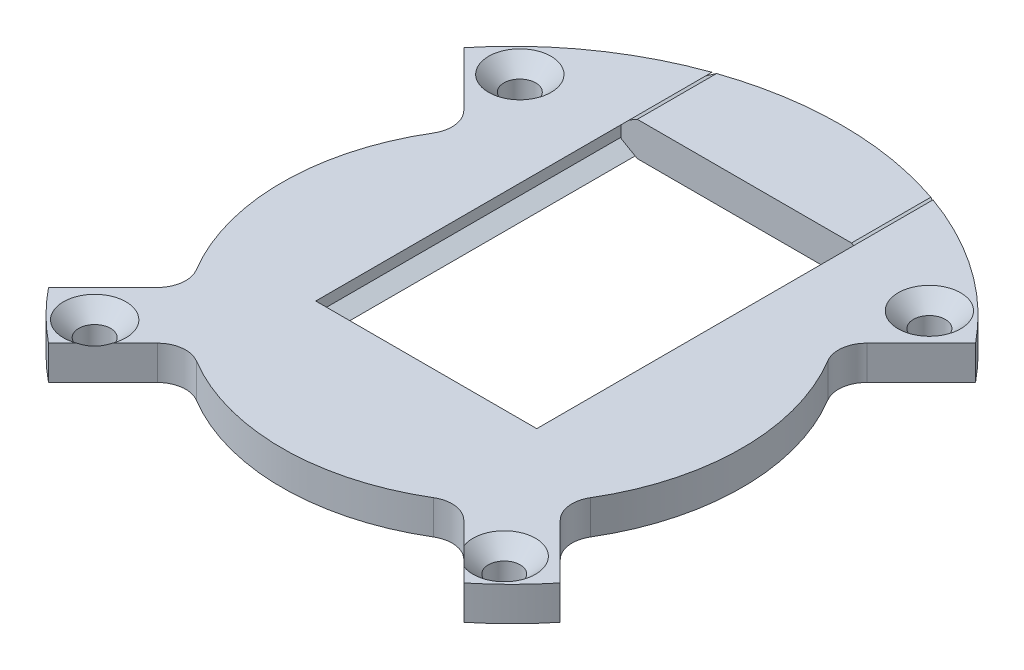
from build123d import *

# Parameters (mm, degrees)
SKETCH1_R                                      = 29
BOSS_EXTRUDE1_DEPTH                            = 1.5
CUT_EXTRUDE1_DEPTH                             = 42.12177039
BOSS_EXTRUDE2_REACH                            = 46.997
BOSS_EXTRUDE2_END_RADIUS                       = 29
BOSS_EXTRUDE3_REACH                            = 59.346
BOSS_EXTRUDE3_END_RADIUS                       = 29
CUT_EXTRUDE8_DEPTH                             = 42.12177039
CSK_FOR_M2_5_FLAT_HEAD_MACHINE_SCREW2_AT_COUNT = 2
CSK_FOR_M2_5_FLAT_HEAD_MACHINE_SCREW2_AT_PITCH = 36.043
CSK_FOR_M2_5_FLAT_HEAD_MACHINE_SCREW_2_COUNT   = 2
CSK_FOR_M2_5_FLAT_HEAD_MACHINE_SCREW_2_PITCH   = 51.950988874
CSK_FOR_M2_5_FLAT_HEAD_MACHINE_SCREW_3_COUNT   = 2
CSK_FOR_M2_5_FLAT_HEAD_MACHINE_SCREW_3_PITCH   = 37.414


with BuildPart() as part:
    # Sketch1 → Boss-Extrude1 (new, symmetric)
    with BuildSketch(Plane(origin=(0, 0, 0), x_dir=(1, 0, 0), z_dir=(0, 1, 0))):
        with Locations(Location((0, 0, 0), (0, 0, 270))):
            Circle(SKETCH1_R)
    extrude(amount=BOSS_EXTRUDE1_DEPTH, both=True)

    # Sketch2 → Cut-Extrude1 (cut, through all)
    with BuildSketch(Plane(origin=(0, 1.5, 0), x_dir=(1, 0, 0), z_dir=(0, 1, 0))):
        Polygon((-11.025, 7.55), (-11.025, 29), (11.025, 29), (11.025, 7.55), (11.025, -7.55), (-11.025, -7.55), align=None)
    extrude(amount=-CUT_EXTRUDE1_DEPTH, mode=Mode.SUBTRACT)

    # Boss-Extrude2: up to this cylinder (the profile starts inside it)
    boss_extrude2_end = Plane(origin=(0, -0.7325095, 0), z_dir=(0, -1, 0)) * Cylinder(BOSS_EXTRUDE2_END_RADIUS, 154.459019, mode=Mode.PRIVATE)
    # Sketch3 → Boss-Extrude2 (add, up to the surface)
    with BuildSketch(Plane(origin=(0, 0, 7.55), x_dir=(-1, 0, 0), z_dir=(0, 0, -1)), mode=Mode.PRIVATE) as boss_extrude2_sk1:
        Polygon((-11.525, -1.5), (-9.725961894, -1.5), (-11.025, -0.75), (-11.025, 0.75), (-9.725961894, 1.5), (-11.525, 1.5), align=None)
    boss_extrude2_tool1 = extrude(boss_extrude2_sk1.sketch, amount=BOSS_EXTRUDE2_REACH, mode=Mode.PRIVATE) & boss_extrude2_end
    add(boss_extrude2_tool1.solids().sort_by_distance((10.625481, -1.465019, 7.55))[0])
    # Sketch3 → Boss-Extrude2 (add, up to the surface)
    with BuildSketch(Plane(origin=(0, 0, 7.55), x_dir=(-1, 0, 0), z_dir=(0, 0, -1)), mode=Mode.PRIVATE) as boss_extrude2_sk2:
        Polygon((11.525, 1.5), (11.525, -1.5), (9.725961894, -1.5), (11.025, -0.75), (11.025, 0.75), (9.725961894, 1.5), align=None)
    boss_extrude2_tool2 = extrude(boss_extrude2_sk2.sketch, amount=BOSS_EXTRUDE2_REACH, mode=Mode.PRIVATE) & boss_extrude2_end
    add(boss_extrude2_tool2.solids().sort_by_distance((-11.490019, 0, 7.55))[0])

    # Sketch17 → Cut-Extrude8 (cut, through all)
    with BuildSketch(Plane(origin=(0, 1.5, 0), x_dir=(1, 0, 0), z_dir=(0, 1, 0))):
        with BuildLine():
            ThreePointArc((-22.517398398, 18.274757711), (-29, 0), (-22.517398398, -18.274757711))
            Line((-22.517398398, -18.274757711), (-17.730812648, -13.488171961))
            ThreePointArc((-17.730812648, -13.488171961), (-17.017188537, -12.024869111), (-17.355878546, -10.432448414))
            ThreePointArc((-17.355878546, -10.432448414), (-20.25, 0), (-17.355878546, 10.432448414))
            ThreePointArc((-17.355878546, 10.432448414), (-17.017188537, 12.024869111), (-17.730812648, 13.488171961))
            Line((-17.730812648, 13.488171961), (-22.517398398, 18.274757711))
        make_face()
        with BuildLine():
            ThreePointArc((-18.274757711, -22.517398398), (0, -29), (18.274757711, -22.517398398))
            Line((18.274757711, -22.517398398), (13.488171961, -17.730812648))
            ThreePointArc((13.488171961, -17.730812648), (12.024869111, -17.017188537), (10.432448414, -17.355878546))
            ThreePointArc((10.432448414, -17.355878546), (0, -20.25), (-10.432448414, -17.355878546))
            ThreePointArc((-10.432448414, -17.355878546), (-12.024869111, -17.017188537), (-13.488171961, -17.730812648))
            Line((-13.488171961, -17.730812648), (-18.274757711, -22.517398398))
        make_face()
        with BuildLine():
            Line((17.730812648, -13.488171961), (22.517398398, -18.274757711))
            ThreePointArc((22.517398398, -18.274757711), (29, 0), (22.517398398, 18.274757711))
            Line((22.517398398, 18.274757711), (17.730812648, 13.488171961))
            ThreePointArc((17.730812648, 13.488171961), (17.017188537, 12.024869111), (17.355878546, 10.432448414))
            ThreePointArc((17.355878546, 10.432448414), (20.25, 0), (17.355878546, -10.432448414))
            ThreePointArc((17.355878546, -10.432448414), (17.017188537, -12.024869111), (17.730812648, -13.488171961))
        make_face()
    extrude(amount=-CUT_EXTRUDE8_DEPTH, mode=Mode.SUBTRACT)

    # Sketch19 → CSK for M2.5 Flat Head Machine Screw2 (revolve, cut)
    with BuildSketch(Plane(origin=(-18.0215, 1.5, -18.707), x_dir=(0, 0, 1), z_dir=(1, 0, 0))):
        Polygon((0, 0), (0, 3), (1.4, 3), (1.4, 1.35), (2.75, 0), align=None)
    csk_for_m2_5_flat_head_machine_screw2 = revolve(axis=Axis((-18.0215, 7.85, -18.707), (0, -1, 0)), mode=Mode.SUBTRACT)

    # CSK for M2.5 Flat Head Machine Screw2 at: CSK for M2.5 Flat Head Machine Screw2 ×2
    with Locations(*[(i * CSK_FOR_M2_5_FLAT_HEAD_MACHINE_SCREW2_AT_PITCH, 0, 0) for i in range(1, CSK_FOR_M2_5_FLAT_HEAD_MACHINE_SCREW2_AT_COUNT)]):
        add(csk_for_m2_5_flat_head_machine_screw2, mode=Mode.SUBTRACT)

    # CSK for M2.5 Flat Head Machine Screw 2: CSK for M2.5 Flat Head Machine Screw2 ×2
    with Locations(*[Vector(0.69378852609191, 0, 0.7201787840968487) * (i * CSK_FOR_M2_5_FLAT_HEAD_MACHINE_SCREW_2_PITCH) for i in range(1, CSK_FOR_M2_5_FLAT_HEAD_MACHINE_SCREW_2_COUNT)]):
        add(csk_for_m2_5_flat_head_machine_screw2, mode=Mode.SUBTRACT)

    # CSK for M2.5 Flat Head Machine Screw 3: CSK for M2.5 Flat Head Machine Screw2 ×2
    with Locations(*[(0, 0, i * CSK_FOR_M2_5_FLAT_HEAD_MACHINE_SCREW_3_PITCH) for i in range(1, CSK_FOR_M2_5_FLAT_HEAD_MACHINE_SCREW_3_COUNT)]):
        add(csk_for_m2_5_flat_head_machine_screw2, mode=Mode.SUBTRACT)


with BuildPart() as body_2:
    # Boss-Extrude3: up to this cylinder (the profile starts inside it)
    boss_extrude3_end = Plane(origin=(0, 0, 0), z_dir=(0, -1, 0)) * Cylinder(BOSS_EXTRUDE3_END_RADIUS, 177.692, mode=Mode.PRIVATE)
    # Sketch6 → Boss-Extrude3 (new, up to the surface)
    with BuildSketch(Plane(origin=(0, 0, -20.45), x_dir=(-1, 0, 0), z_dir=(0, 0, -1)), mode=Mode.PRIVATE) as boss_extrude3_sk1:
        Polygon((9.425961894, -1.5), (-9.425961894, -1.5), (-10.875, -0.66339746), (-10.875, 0.66339746), (-9.425961894, 1.5), (9.425961894, 1.5), (10.875, 0.66339746), (10.875, -0.66339746), align=None)
    boss_extrude3_tool1 = extrude(boss_extrude3_sk1.sketch, amount=BOSS_EXTRUDE3_REACH, mode=Mode.PRIVATE) & boss_extrude3_end
    add(boss_extrude3_tool1.solids().sort_by_distance((0, 0, -20.45))[0])


solid = Compound([part.part, body_2.part])
